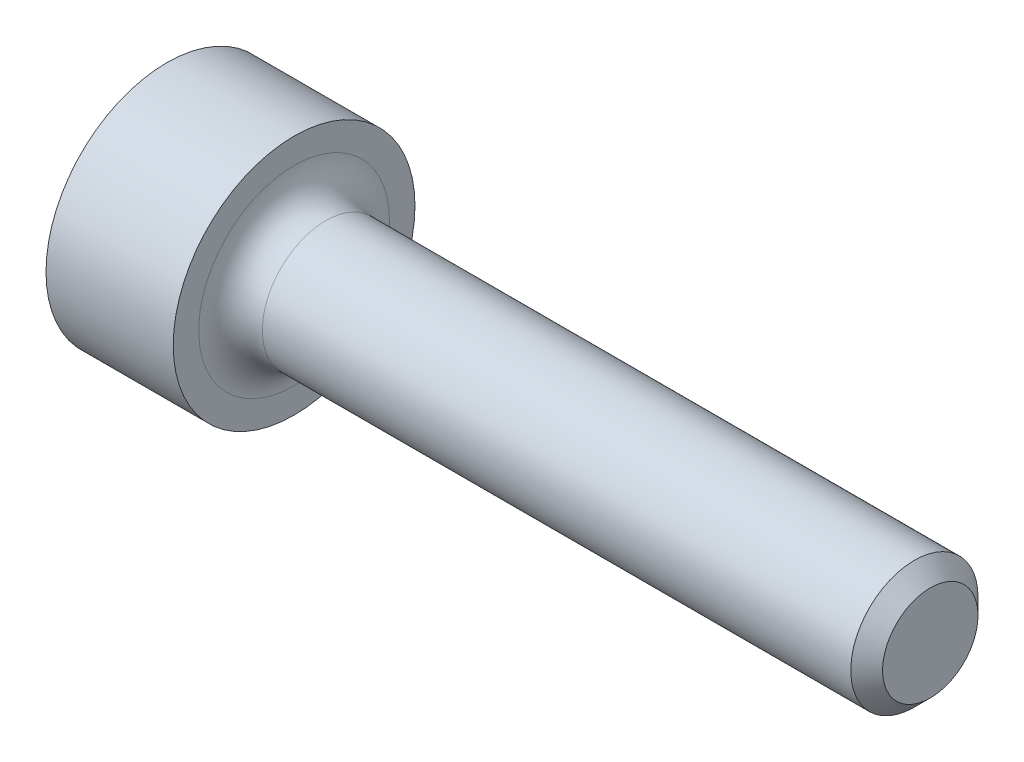
from build123d import *

# Parameters (mm, degrees)
FILLET_1_R          = 0.5
CUT_EXTRUDE_2_DEPTH = 1
CHAMFER_3_SIZE      = 0.25


with BuildPart() as part:
    # Эскиз2 → Повернуть1 (revolve)
    with BuildSketch(Plane.XY):
        Polygon((0, 0), (0, -1.9), (2, -1.9), (2, -1), (12, -1), (12, 0), align=None)
    revolve(axis=Axis((0, 0, 0), (1, 0, 0)))

    # Скругление1
    fillet_1_edges = [part.edges().sort_by_distance(p)[0] for p in [
        (2, 1, 0),
    ]]
    fillet(fillet_1_edges, radius=FILLET_1_R)

    # Эскиз3 → Вырез-Вытянуть2 (cut)
    with BuildSketch(Plane.ZY):
        Polygon((0, 0.866025404), (-0.75, 0.433012702), (-0.75, -0.433012702), (0, -0.866025404), (0.75, -0.433012702), (0.75, 0.433012702), align=None)
    extrude(amount=-CUT_EXTRUDE_2_DEPTH, mode=Mode.SUBTRACT)

    # Эскиз5 → Вырез-Повернуть1 (revolve, cut)
    with BuildSketch(Plane.XY):
        Polygon((1, -0.866025404), (1, 0), (1.5, 0), align=None)
    revolve(axis=Axis((1, 0, 0), (1, 0, 0)), mode=Mode.SUBTRACT)

    # Фаска3
    chamfer_3_edges = [part.edges().sort_by_distance(p)[0] for p in [
        (12, 1, 0),
    ]]
    chamfer(chamfer_3_edges, length=CHAMFER_3_SIZE)


solid = part.part
